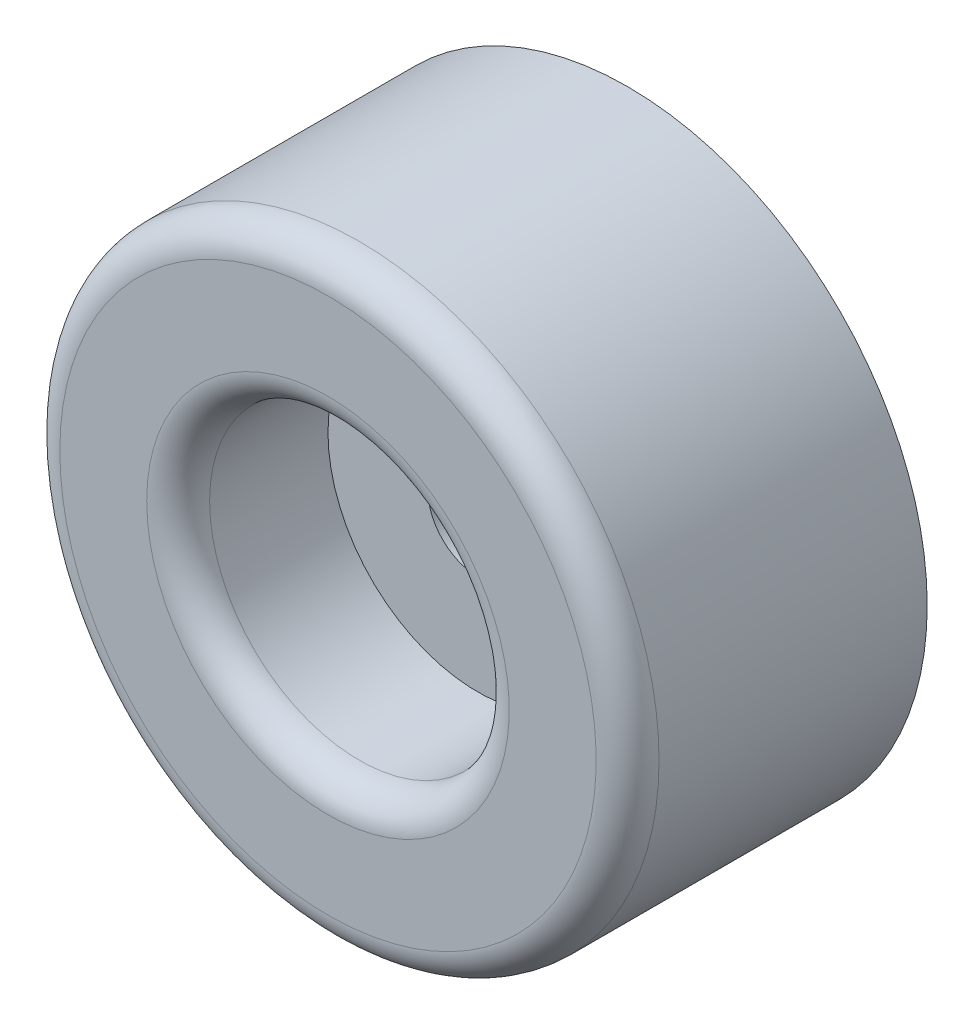
from build123d import *

# Parameters (mm, degrees)
FILLET1_R = 2


with BuildPart() as part:
    # Sketch1 → Revolve1 (revolve)
    with BuildSketch(Plane(origin=(0, 0, 0), x_dir=(0, 0, -1), z_dir=(1, 0, 0))):
        Polygon((0, 3.175), (0, 19.05), (-19.05, 19.05), (-19.05, 9.525), (-9.525, 9.525), (-9.525, 3.175), align=None)
    revolve(axis=Axis((0, 0, 13.147296845), (0, 0, -1)))

    # Fillet1
    fillet1_edges = [part.edges().sort_by_distance(p)[0] for p in [
        (0, -9.525, 19.05),
        (0, -19.05, 19.05),
    ]]
    fillet(fillet1_edges, radius=FILLET1_R)


solid = part.part
